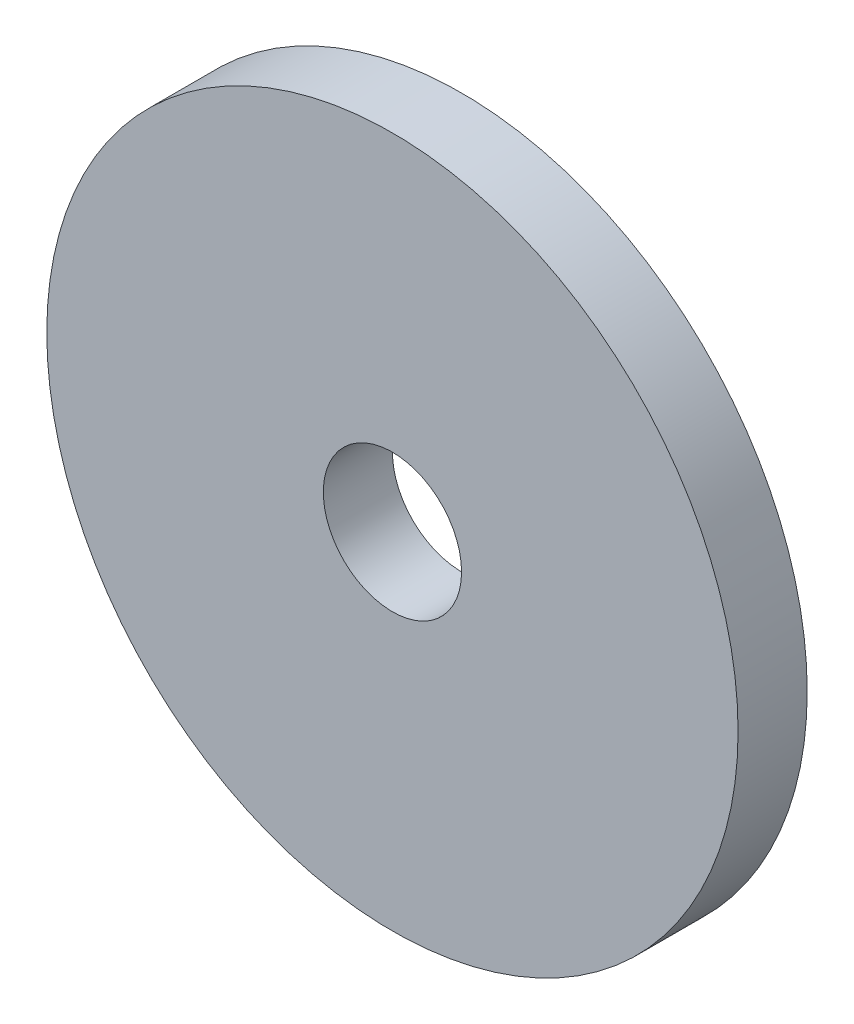
from build123d import *

# Parameters (mm, degrees)
SKETCH1_R           = 15
SKETCH1_R_2         = 3
BOSS_EXTRUDE1_DEPTH = 3


with BuildPart() as part:
    # Sketch1 → Boss-Extrude1 (new body)
    with BuildSketch(Plane.XY):
        with Locations((-85, 68)):
            Circle(SKETCH1_R)
        with Locations((-85, 68)):
            Circle(SKETCH1_R_2, mode=Mode.SUBTRACT)
    extrude(amount=BOSS_EXTRUDE1_DEPTH)


solid = part.part
